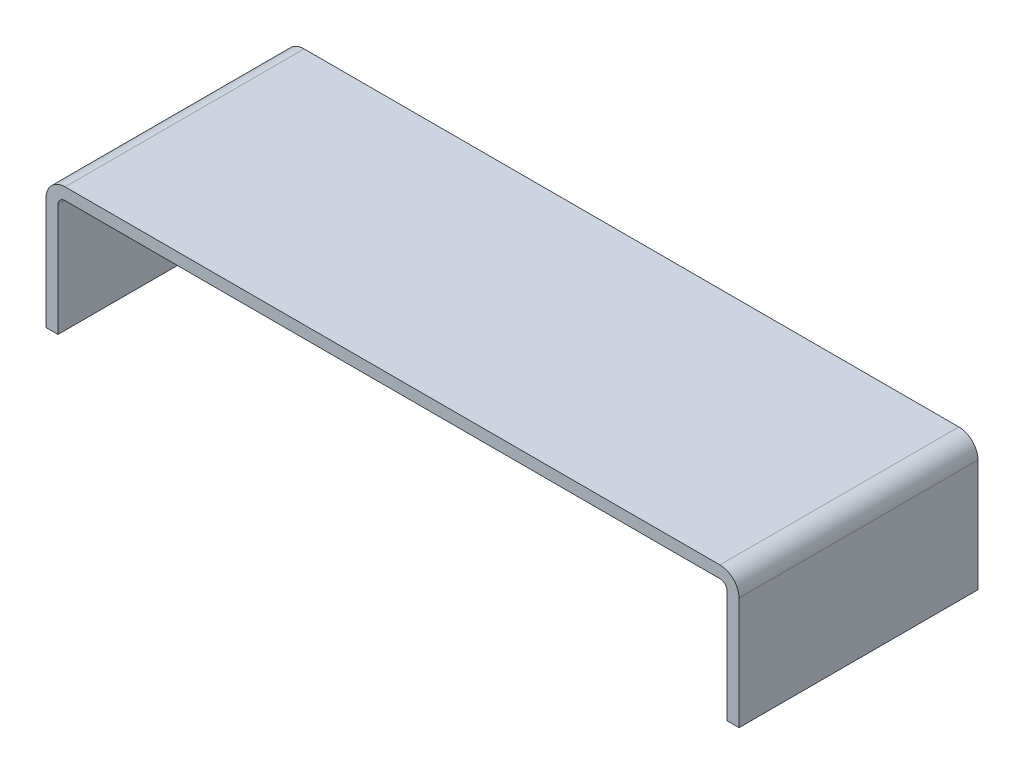
from build123d import *

# Parameters (mm, degrees)
EXTRUDE_THIN1_DEPTH = 12.7


with BuildPart() as part:
    # Sketch1 → Extrude-Thin1 (new body, symmetric)
    with BuildSketch(Plane.XY):
        with BuildLine():
            Line((-35.56, -12.7), (-35.56, -0.762))
            ThreePointArc((-35.56, -0.762), (-35.336815367, -0.223184633), (-34.798, 0))
            Line((-34.798, 0), (34.798, 0))
            ThreePointArc((34.798, 0), (35.336815367, -0.223184633), (35.56, -0.762))
            Line((35.56, -0.762), (35.56, -12.7))
            Line((35.56, -12.7), (36.83, -12.7))
            Line((36.83, -12.7), (36.83, -0.762))
            ThreePointArc((36.83, -0.762), (36.234840979, 0.674840979), (34.798, 1.27))
            Line((34.798, 1.27), (-34.798, 1.27))
            ThreePointArc((-34.798, 1.27), (-36.234840979, 0.674840979), (-36.83, -0.762))
            Line((-36.83, -0.762), (-36.83, -12.7))
            Line((-36.83, -12.7), (-35.56, -12.7))
        make_face()
    extrude(amount=EXTRUDE_THIN1_DEPTH, both=True)


solid = part.part
